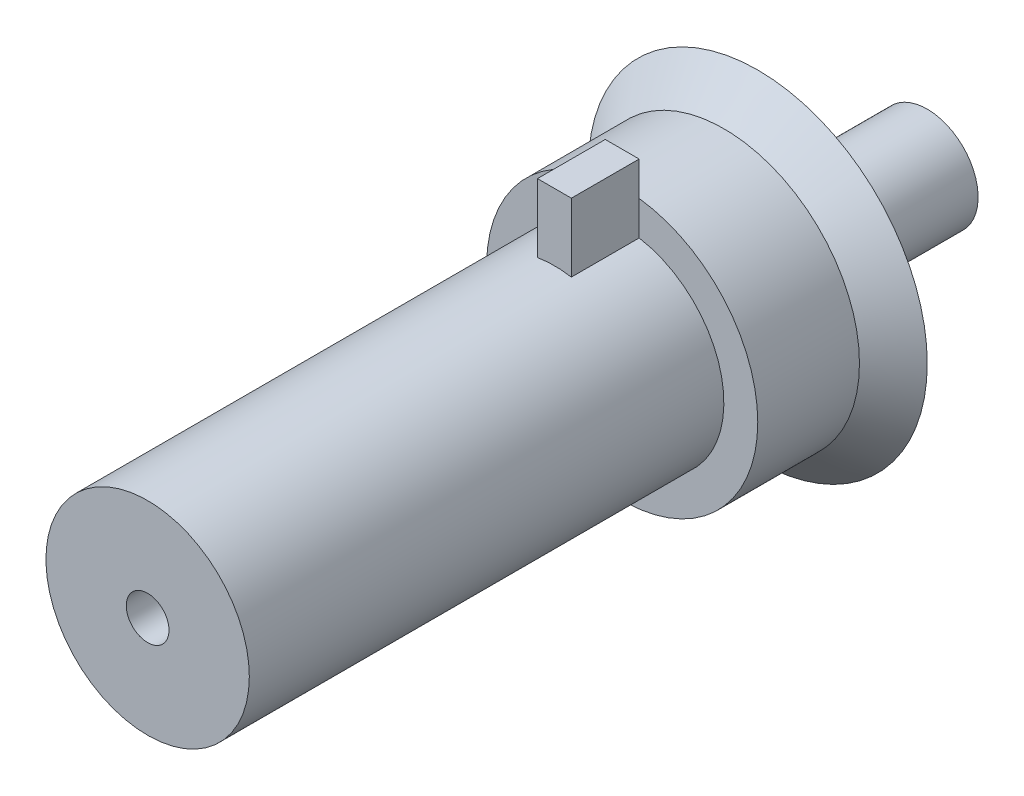
from build123d import *

# Parameters (mm, degrees)
SKETCH1_R           = 15
BOSS_EXTRUDE1_DEPTH = 80
SKETCH1_2_R         = 15
SKETCH2_R           = 25
SKETCH3_R           = 7.5
BOSS_EXTRUDE2_DEPTH = 25
SKETCH4_W           = 5
SKETCH4_H           = 25
BOSS_EXTRUDE3_DEPTH = 10
SKETCH5_R           = 3.15
CUT_EXTRUDE1_DEPTH  = 6
SKETCH6_R           = 20
BOSS_EXTRUDE4_DEPTH = 15


with BuildPart() as part:
    # Sketch1 → Boss-Extrude1 (new body)
    with BuildSketch(Plane.XY):
        Circle(SKETCH1_R)
    extrude(amount=BOSS_EXTRUDE1_DEPTH)

    # Sketch1_2 → Loft1 section 0
    with BuildSketch(Plane.XY):
        Circle(SKETCH1_2_R)
    # Sketch2 → Loft1 section 1
    with BuildSketch(Plane(origin=(0, 0, -10), x_dir=(-1, 0, 0), z_dir=(0, 0, -1))):
        Circle(SKETCH2_R)
    loft()

    # Sketch3 → Boss-Extrude2 (add)
    with BuildSketch(Plane(origin=(0, 0, -10), x_dir=(-1, 0, 0), z_dir=(0, 0, -1))):
        Circle(SKETCH3_R)
    extrude(amount=BOSS_EXTRUDE2_DEPTH)

    # Sketch4 → Boss-Extrude3 (add)
    with BuildSketch(Plane.XY.offset(10)):
        with Locations((0.003158662, 12.374368268)):
            Rectangle(SKETCH4_W, SKETCH4_H)
    extrude(amount=BOSS_EXTRUDE3_DEPTH)

    # Sketch5 → Cut-Extrude1 (cut)
    with BuildSketch(Plane.XY.offset(80)):
        Circle(SKETCH5_R)
    extrude(amount=-CUT_EXTRUDE1_DEPTH, mode=Mode.SUBTRACT)

    # Sketch6 → Boss-Extrude4 (add)
    with BuildSketch(Plane.XY.offset(10)):
        Circle(SKETCH6_R)
    extrude(amount=-BOSS_EXTRUDE4_DEPTH)


solid = part.part
